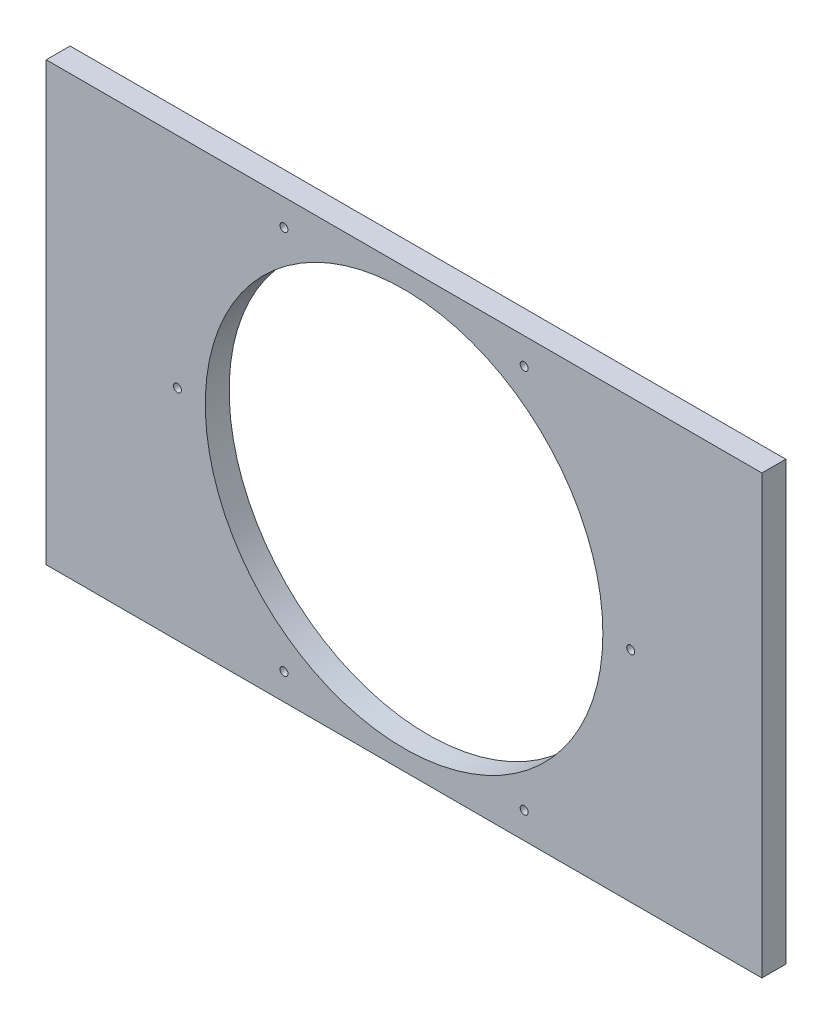
from build123d import *

# Parameters (mm, degrees)
SKETCH1_W           = 180
SKETCH1_H           = 110
BOSS_EXTRUDE1_DEPTH = 6
SKETCH2_R           = 50
CUT_EXTRUDE1_DEPTH  = 6
SKETCH4_R           = 1
CUT_EXTRUDE2_DEPTH  = 40


with BuildPart() as part:
    # Sketch1 → Boss-Extrude1 (new body)
    with BuildSketch(Plane.XY):
        with Locations((90, 55)):
            Rectangle(SKETCH1_W, SKETCH1_H)
    extrude(amount=BOSS_EXTRUDE1_DEPTH)

    # Sketch2 → Cut-Extrude1 (cut)
    with BuildSketch(Plane.XY):
        with Locations((90, 55)):
            Circle(SKETCH2_R)
    extrude(amount=CUT_EXTRUDE1_DEPTH, mode=Mode.SUBTRACT)

    # Sketch4 → Cut-Extrude2 (cut)
    with BuildSketch(Plane.XY):
        with Locations((59.794601939, 103.338741481)):
            Circle(SKETCH4_R)
        with Locations((120.205398061, 103.338741481)):
            Circle(SKETCH4_R)
        with Locations((147, 55)):
            Circle(SKETCH4_R)
        with Locations((120.205398061, 6.661258519)):
            Circle(SKETCH4_R)
        with Locations((59.794601939, 6.661258519)):
            Circle(SKETCH4_R)
        with Locations((33, 55)):
            Circle(SKETCH4_R)
    extrude(amount=CUT_EXTRUDE2_DEPTH, mode=Mode.SUBTRACT)


solid = part.part
